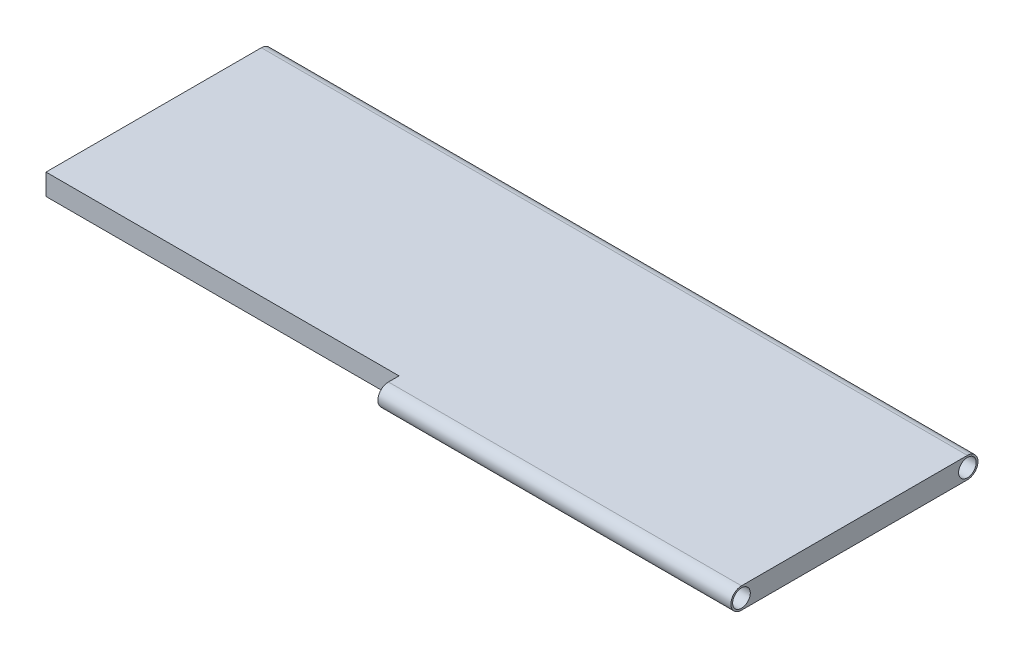
from build123d import *

# Parameters (mm, degrees)
SKETCH1_W           = 1000
SKETCH1_H           = 290
BOSS_EXTRUDE1_DEPTH = 30
SKETCH2_R           = 15
SKETCH2_R_2         = 12.5
BOSS_EXTRUDE2_DEPTH = 500
SKETCH3_R           = 15
SKETCH3_R_2         = 12.5
BOSS_EXTRUDE3_DEPTH = 1000


with BuildPart() as part:
    # Sketch1 → Boss-Extrude1 (new body)
    with BuildSketch(Plane(origin=(0, 0, 0), x_dir=(1, 0, 0), z_dir=(0, 1, 0))):
        Rectangle(SKETCH1_W, SKETCH1_H)
    extrude(amount=BOSS_EXTRUDE1_DEPTH)

    # Sketch2 → Boss-Extrude2 (add)
    with BuildSketch(Plane(origin=(500, 0, 0), x_dir=(0, 0, -1), z_dir=(1, 0, 0))):
        with BuildLine():
            Line((-145, 30), (-160, 30))
            ThreePointArc((-160, 30), (-149.393398282, 25.606601718), (-145, 15))
            Line((-145, 15), (-145, 30))
        make_face()
        with BuildLine():
            Line((-145, 0), (-145, 15))
            ThreePointArc((-145, 15), (-149.393398282, 4.393398282), (-160, 0))
            Line((-160, 0), (-145, 0))
        make_face()
        with Locations((-160, 15)):
            Circle(SKETCH2_R)
        with Locations((-160, 15)):
            Circle(SKETCH2_R_2, mode=Mode.SUBTRACT)
    extrude(amount=-BOSS_EXTRUDE2_DEPTH)

    # Sketch3 → Boss-Extrude3 (add)
    with BuildSketch(Plane(origin=(500, 0, 0), x_dir=(0, 0, -1), z_dir=(1, 0, 0))):
        with BuildLine():
            ThreePointArc((145, 15), (149.393398282, 25.606601718), (160, 30))
            Line((160, 30), (145, 30))
            Line((145, 30), (145, 15))
        make_face()
        with Locations((160, 15)):
            Circle(SKETCH3_R)
        with Locations((160, 15)):
            Circle(SKETCH3_R_2, mode=Mode.SUBTRACT)
        with BuildLine():
            ThreePointArc((160, 0), (149.393398282, 4.393398282), (145, 15))
            Line((145, 15), (145, 0))
            Line((145, 0), (160, 0))
        make_face()
    extrude(amount=-BOSS_EXTRUDE3_DEPTH)


solid = part.part
